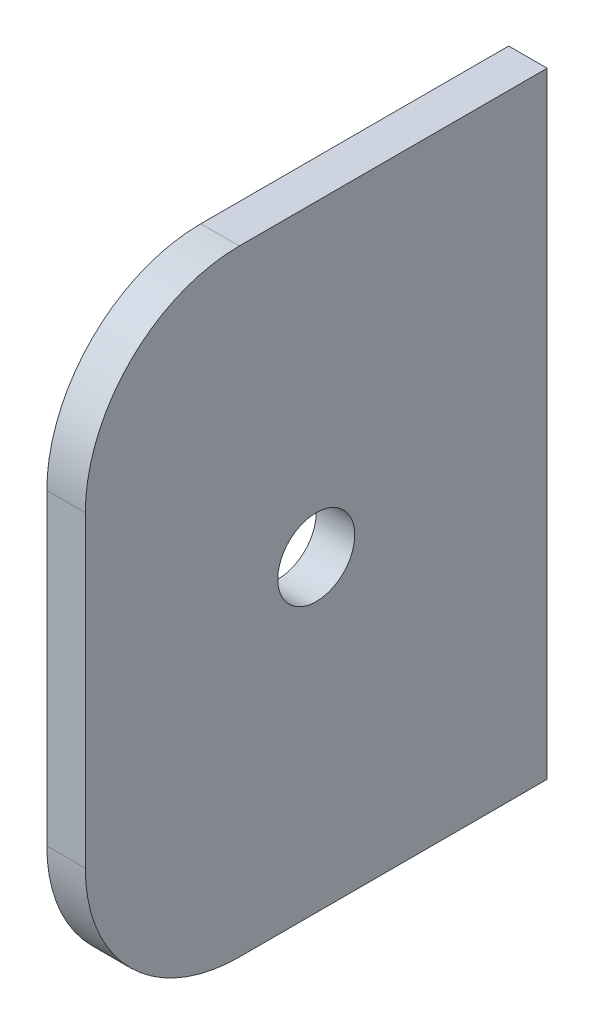
from build123d import *

# Parameters (mm, degrees)
SKETCH1_W           = 3.175
SKETCH1_H           = 50.8
BOSS_EXTRUDE1_DEPTH = 38.1
SKETCH3_R           = 3.175
CUT_EXTRUDE1_DEPTH  = 38.1
FILLET1_R           = 12.7


with BuildPart() as part:
    # Sketch1 → Boss-Extrude1 (new body)
    with BuildSketch(Plane.XY):
        with Locations((17.4625, -24.384)):
            Rectangle(SKETCH1_W, SKETCH1_H)
    extrude(amount=BOSS_EXTRUDE1_DEPTH)

    # Sketch3 → Cut-Extrude1 (cut)
    with BuildSketch(Plane.ZY.offset(-15.875)):
        with Locations((19.05, -24.384)):
            Circle(SKETCH3_R)
    extrude(amount=-CUT_EXTRUDE1_DEPTH, mode=Mode.SUBTRACT)

    # Fillet1
    fillet1_edges = [part.edges().sort_by_distance(p)[0] for p in [
        (17.4625, -49.784, 38.1),
        (17.4625, 1.016, 38.1),
    ]]
    fillet(fillet1_edges, radius=FILLET1_R)


solid = part.part
